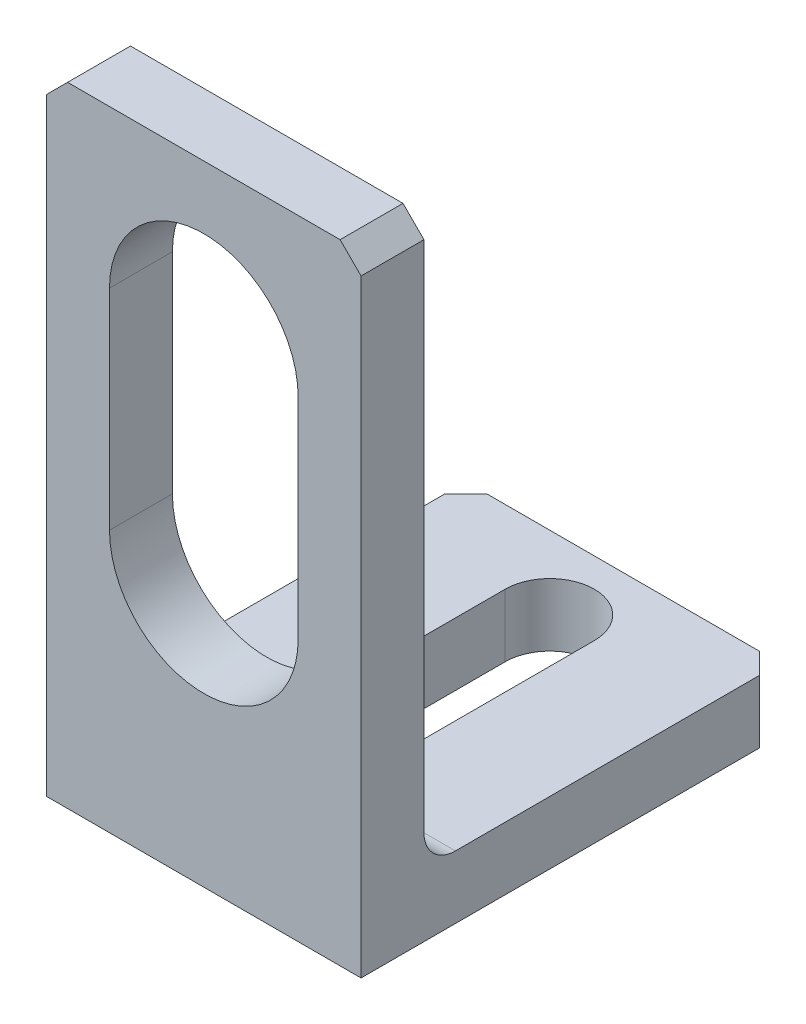
from build123d import *

# Parameters (mm, degrees)
SKETCH1_W           = 30
SKETCH1_H           = 60
BOSS_EXTRUDE1_DEPTH = 3
SKETCH3_W           = 30
SKETCH3_H           = 34
BOSS_EXTRUDE2_DEPTH = 6
FILLET1_R           = 3
CHAMFER1_SIZE       = 2


with BuildPart() as part:
    # Sketch1 → Boss-Extrude1 (new body, symmetric)
    with BuildSketch(Plane.XY):
        with Locations((0, 30)):
            Rectangle(SKETCH1_W, SKETCH1_H)
        with BuildLine():
            Line((9, 45), (9, 25))
            ThreePointArc((9, 25), (0, 16), (-9, 25))
            Line((-9, 25), (-9, 45))
            ThreePointArc((-9, 45), (0, 54), (9, 45))
        make_face(mode=Mode.SUBTRACT)
    extrude(amount=BOSS_EXTRUDE1_DEPTH, both=True)

    # Sketch3 → Boss-Extrude2 (add)
    with BuildSketch(Plane(origin=(0, 0, 0), x_dir=(1, 0, 0), z_dir=(0, 1, 0))):
        with Locations((0, 20)):
            Rectangle(SKETCH3_W, SKETCH3_H)
        with BuildLine():
            Line((4.25, 30), (4.25, 12))
            ThreePointArc((4.25, 12), (0, 7.75), (-4.25, 12))
            Line((-4.25, 12), (-4.25, 30))
            ThreePointArc((-4.25, 30), (0, 34.25), (4.25, 30))
        make_face(mode=Mode.SUBTRACT)
    extrude(amount=BOSS_EXTRUDE2_DEPTH)

    # Fillet1
    fillet1_edges = [part.edges().sort_by_distance(p)[0] for p in [
        (0, 6, -3),
    ]]
    fillet(fillet1_edges, radius=FILLET1_R)

    # Chamfer1
    chamfer1_edges = [part.edges().sort_by_distance(p)[0] for p in [
        (-15, 3, -37),
        (15, 3, -37),
        (-15, 60, 0),
        (15, 60, 0),
    ]]
    chamfer(chamfer1_edges, length=CHAMFER1_SIZE)


solid = part.part
